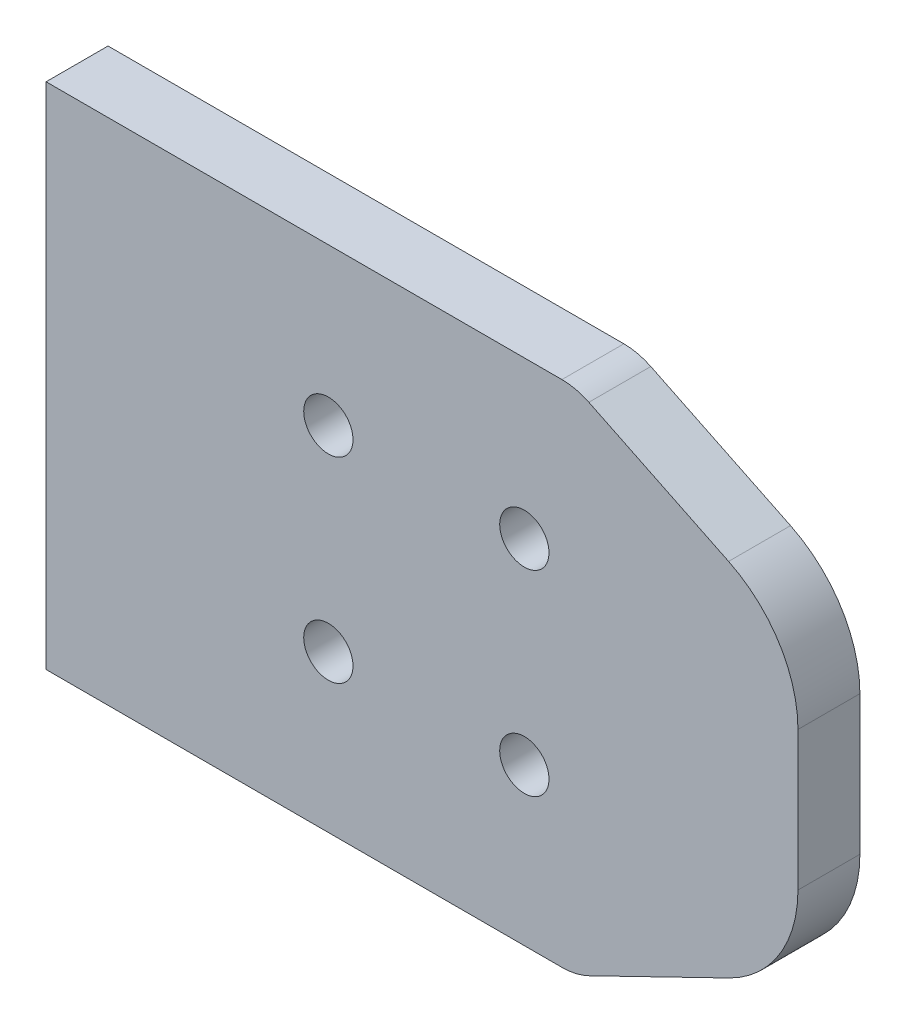
from build123d import *

# Parameters (mm, degrees)
SKETCH1_W      = 122
SKETCH1_H      = 82.6
EXTRUDE1_DEPTH = 10.05
SKETCH2_R      = 4
EXTRUDE2_DEPTH = 11.05
EXTRUDE3_DEPTH = 11.05
FILLET1_R      = 10
FILLET2_R      = 20


with BuildPart() as part:
    # Sketch1 → Extrude1 (new body)
    with BuildSketch(Plane.XY):
        with Locations((-29.941398377, -6.923807929)):
            Rectangle(SKETCH1_W, SKETCH1_H)
    extrude(amount=EXTRUDE1_DEPTH)

    # Sketch2 → Extrude2 (cut, through all)
    with BuildSketch(Plane(origin=(0, 0, 0), x_dir=(-1, 0, 0), z_dir=(0, 0, -1))):
        with Locations((45.141398377, 8.976192071)):
            Circle(SKETCH2_R)
        with Locations((45.141398377, -22.823807929)):
            Circle(SKETCH2_R)
        with Locations((13.341398377, 8.976192071)):
            Circle(SKETCH2_R)
        with Locations((13.341398377, -22.823807929)):
            Circle(SKETCH2_R)
    extrude(amount=-EXTRUDE2_DEPTH, mode=Mode.SUBTRACT)

    # Sketch3 → Extrude3 (cut, through all)
    with BuildSketch(Plane(origin=(0, 0, 0), x_dir=(-1, 0, 0), z_dir=(0, 0, -1))):
        Polygon((4.941398377, 34.376192071), (-31.058601623, 16.876192071), (-39.457911359, 42.934117224), align=None)
        Polygon((-31.058601623, -30.723807929), (-39.457911359, -56.781733081), (4.941398377, -48.223807929), align=None)
    extrude(amount=-EXTRUDE3_DEPTH, mode=Mode.SUBTRACT)

    # Fillet1
    fillet1_edges = [part.edges().sort_by_distance(p)[0] for p in [
        (-4.941398377, 34.376192071, 5.025),
        (-4.941398377, -48.223807929, 5.025),
    ]]
    fillet(fillet1_edges, radius=FILLET1_R)

    # Fillet2
    fillet2_edges = [part.edges().sort_by_distance(p)[0] for p in [
        (31.058601623, 16.876192071, 5.025),
        (31.058601623, -30.723807929, 5.025),
    ]]
    fillet(fillet2_edges, radius=FILLET2_R)


solid = part.part
